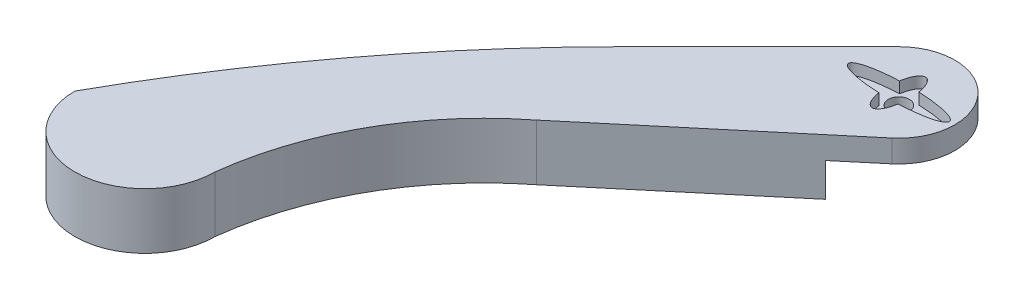
from build123d import *

# Parameters (mm, degrees)
EXTRUDE_1_DEPTH          = 10
SKETCH_2_R               = 3.75
CUT_EXTRUDE_2_DEPTH      = 21
CUT_EXTRUDE_2_DEPTH_BACK = 1
CUT_EXTRUDE_3_DEPTH      = 4
CUT_EXTRUDE_3_DEPTH_BACK = 4
CUT_EXTRUDE_4_DEPTH      = 12


with BuildPart() as part:
    # 草图1 → 凸台-拉伸1 (new body, symmetric)
    with BuildSketch(Plane(origin=(0, 0, 0), x_dir=(1, 0, 0), z_dir=(0, 1, 0))):
        with BuildLine():
            Line((-14.142135624, 14.142135624), (-63.639610307, -35.355339059))
            ThreePointArc((-63.639610307, -35.355339059), (-109.455133557, -88.069120133), (-147.47848225, -146.652648876))
            ThreePointArc((-147.47848225, -146.652648876), (-122.47848225, -171.652648876), (-97.47848225, -146.652648876))
            ThreePointArc((-97.47848225, -146.652648876), (-84.10519624, -105.787977439), (-56.088247687, -73.171773734))
            Line((-56.088247687, -73.171773734), (12.855752194, -15.320888862))
            ThreePointArc((12.855752194, -15.320888862), (14.745546736, 13.511804152), (-14.142135624, 14.142135624))
        make_face()
    extrude(amount=EXTRUDE_1_DEPTH, both=True)

    # 草图2 → 切除-拉伸2 (cut, two sides)
    with BuildSketch(Plane(origin=(0, 10, 0), x_dir=(-1, 0, 0), z_dir=(0, -1, 0))) as cut_extrude_2_sk:
        Circle(SKETCH_2_R)
    extrude(amount=CUT_EXTRUDE_2_DEPTH, mode=Mode.SUBTRACT)
    extrude(cut_extrude_2_sk.sketch, amount=-CUT_EXTRUDE_2_DEPTH_BACK, mode=Mode.SUBTRACT)

    # 草图3 → 切除-拉伸3 (cut, two sides)
    with BuildSketch(Plane(origin=(0, 10, 0), x_dir=(-1, 0, 0), z_dir=(0, -1, 0))) as cut_extrude_3_sk:
        with BuildLine():
            add(Edge.make_bspline(
                [(-3.457188478, 3.680182522), (-18, 3.087230439), (-18, 0), (-18, -3.087230439), (-3.457188478, -3.680182522)],
                knots=[1.764063263, 1.764063263, 1.764063263, 3.141592654, 3.141592654, 4.519122044, 4.519122044, 4.519122044], degree=2, weights=[1, 0.772031744, 1, 0.772031744, 1]))
            add(Edge.make_bspline(
                [(-3.457188478, -3.680182522), (0, -24.523240209), (3.457188478, -3.680182522)],
                knots=[1.968592603, 1.968592603, 1.968592603, 4.314592705, 4.314592705, 4.314592705], degree=2, weights=[1, 0.387387634, 1]))
            add(Edge.make_bspline(
                [(3.457188478, -3.680182522), (18, -3.087230439), (18, 0), (18, 3.087230439), (3.457188478, 3.680182522)],
                knots=[4.905655917, 4.905655917, 4.905655917, 6.283185307, 6.283185307, 7.660714698, 7.660714698, 7.660714698], degree=2, weights=[1, 0.772031744, 1, 0.772031744, 1]))
            add(Edge.make_bspline(
                [(3.457188478, 3.680182522), (0, 24.523240209), (-3.457188478, 3.680182522)],
                knots=[5.110185256, 5.110185256, 5.110185256, 7.456185358, 7.456185358, 7.456185358], degree=2, weights=[1, 0.387387634, 1]))
        make_face()
    extrude(amount=CUT_EXTRUDE_3_DEPTH, mode=Mode.SUBTRACT)
    extrude(cut_extrude_3_sk.sketch, amount=-CUT_EXTRUDE_3_DEPTH_BACK, mode=Mode.SUBTRACT)

    # 草图4 → 切除-拉伸4 (cut)
    with BuildSketch(Plane(origin=(0, -10, 0), x_dir=(-1, 0, 0), z_dir=(0, -1, 0))):
        with BuildLine():
            Line((0, -26.108145787), (54.796803902, -26.512532655))
            Line((54.796803902, -26.512532655), (14.772467095, 13.511804152))
            ThreePointArc((14.772467095, 13.511804152), (-14.441332679, 13.851832142), (-12.855752194, -15.320888862))
            Line((-12.855752194, -15.320888862), (0, -26.108145787))
        make_face()
    extrude(amount=-CUT_EXTRUDE_4_DEPTH, mode=Mode.SUBTRACT)


solid = part.part
